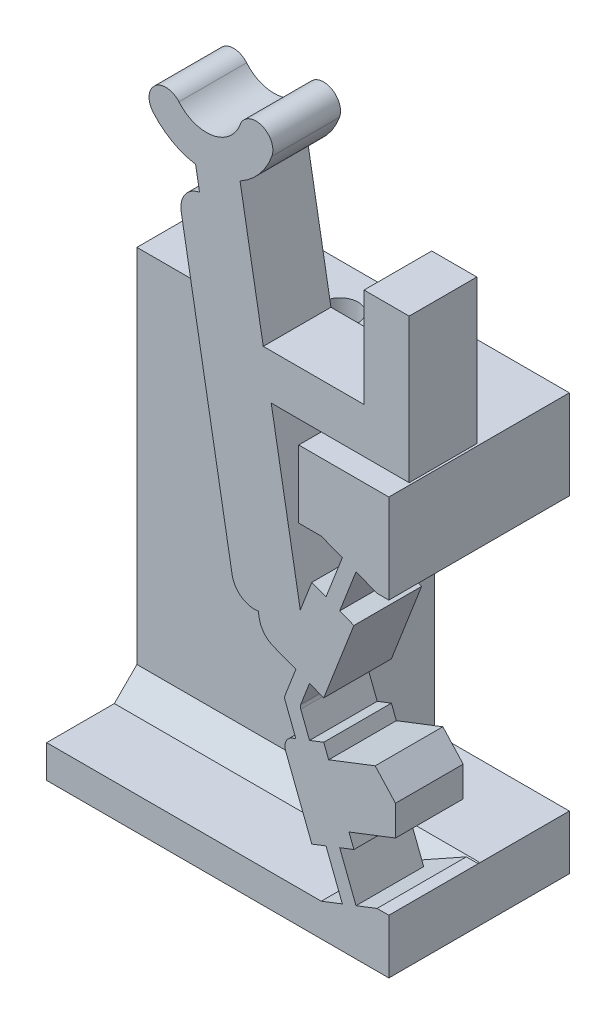
from build123d import *

# Parameters (mm, degrees)
BOSS_SWITCH_BODY_DEPTH            = 3
SKETCH1_W                         = 2.994375291
SKETCH1_H                         = 2.409101515
SKETCH1_W_2                       = 3.994375291
SKETCH1_H_2                       = 3.957767538
BOSS_FLANGE_WIDTH_DEPTH           = 5
BOSS_FLANGE_HEIGHT_REACH          = 36.354
SKETCH2_W                         = 4
SKETCH2_H                         = 3.957767538
SKETCH2_W_2                       = 8
SKETCH2_H_2                       = 1.451333978
SKETCH17_W                        = 15.1675
SKETCH17_H                        = 4
BOSS_FLANGE_SUPPORT_DEPTH         = 13.053634428
CUT_WALL_GAP_DEPTH                = 1
TAP_DRILL_FOR_M2X0_4_TAP1_D       = 1.6
M2_CLEARANCE_HOLE2_D              = 2.4
M2_CLEARANCE_HOLE2_DEPTH          = 13.462735941
CHAMFER_FLANGE_SUPPORT_3_SIZE     = 1
FILLET1_R                         = 1
FILLET2_R                         = 0.5
SKETCH28_W                        = 5.9675
SKETCH28_H                        = 12.095866891
CUT_PRINT_SUPPORT_CLEARANCE_DEPTH = 33.624103931


with BuildPart() as part:
    # Sketch-SwitchBossUp → Boss-Switch Body (new body)
    with BuildSketch(Plane.XY):
        with BuildLine():
            Line((-5.697895702, 26.949658376), (-5.524247524, 25.964850623))
            ThreePointArc((-5.524247524, 25.964850623), (-6.169751391, 25.553619307), (-6.3354071, 24.806394693))
            Line((-6.3354071, 24.806394693), (-4.07798079, 12.003893904))
            ThreePointArc((-4.07798079, 12.003893904), (-3.666749473, 11.358390037), (-2.919524859, 11.192734328))
            Line((-2.919524859, 11.192734328), (-2.775521101, 10.376048434))
            Line((-2.775521101, 10.376048434), (-1.884274871, 10.03057987))
            Line((-1.884274871, 10.03057987), (-1.254903211, 9.786620214))
            Line((-1.254903211, 9.786620214), (-1.735258621, 8.547390389))
            ThreePointArc((-1.735258621, 8.547390389), (-1.752158006, 8.457034961), (-1.735258621, 8.366679532))
            Line((-1.735258621, 8.366679532), (-1.254903211, 7.127449707))
            Line((-1.254903211, 7.127449707), (-1.884274871, 6.883490051))
            Line((-1.884274871, 6.883490051), (-0.547014535, 3.433600952))
            Line((-0.547014535, 3.433600952), (0.082357125, 3.677560608))
            Line((0.082357125, 3.677560608), (0.805200549, 1.81275569))
            Line((0.805200549, 1.81275569), (-0.12720191, 1.451333978))
            Line((-0.12720191, 1.451333978), (-0.12720191, 0))
            Line((-0.12720191, 0), (2.867173381, 0))
            Line((2.867173381, 0), (2.867173381, 2.409101515))
            Line((2.867173381, 2.409101515), (2.343664607, 2.409101515))
            Line((2.343664607, 2.409101515), (1.411262148, 2.047679803))
            Line((1.411262148, 2.047679803), (0.688418723, 3.912484721))
            Line((0.688418723, 3.912484721), (1.317790383, 4.156444377))
            Line((1.317790383, 4.156444377), (1.099194858, 4.720381179))
            Line((1.099194858, 4.720381179), (3.161331824, 5.519715271))
            Line((3.161331824, 5.519715271), (3.161331824, 6.855167315))
            Line((3.161331824, 6.855167315), (2.261147576, 7.841686204))
            Line((2.261147576, 7.841686204), (0.199125572, 7.042396674))
            Line((0.199125572, 7.042396674), (-0.019469953, 7.606333476))
            Line((-0.019469953, 7.606333476), (-0.648841612, 7.36237382))
            Line((-0.648841612, 7.36237382), (-1.038134762, 8.366679532))
            ThreePointArc((-1.038134762, 8.366679532), (-1.055034148, 8.457034961), (-1.038134762, 8.547390389))
            Line((-1.038134762, 8.547390389), (-0.648841612, 9.551696101))
            Line((-0.648841612, 9.551696101), (-0.019469953, 9.307736445))
            Line((-0.019469953, 9.307736445), (1.317790383, 12.757625544))
            Line((1.317790383, 12.757625544), (0.688418723, 13.0015852))
            Line((0.688418723, 13.0015852), (1.411262148, 14.866390118))
            Line((1.411262148, 14.866390118), (2.343664607, 14.504968406))
            Line((2.343664607, 14.504968406), (2.867173381, 14.504968406))
            Line((2.867173381, 14.504968406), (2.867173381, 18.462735944))
            Line((2.867173381, 18.462735944), (-0.111637615, 18.462735944))
            Line((-0.111637615, 18.462735944), (-1.12720191, 18.462735944))
            Line((-1.12720191, 18.462735944), (-1.12720191, 15.462735944))
            Line((-1.12720191, 15.462735944), (-0.12720191, 15.462735944))
            Line((-0.12720191, 15.462735944), (0.805200549, 15.101314231))
            Line((0.805200549, 15.101314231), (0.082357125, 13.236509313))
            Line((0.082357125, 13.236509313), (-0.547014535, 13.480468969))
            Line((-0.547014535, 13.480468969), (-1.059112089, 12.159350171))
            Line((-1.059112089, 12.159350171), (-2.346896051, 19.462735944))
            Line((-2.346896051, 19.462735944), (3.767173381, 19.462735944))
            Line((3.767173381, 19.462735944), (3.767173381, 25.857619356))
            Line((3.767173381, 25.857619356), (1.767173381, 25.857619356))
            Line((1.767173381, 25.857619356), (1.767173381, 21.462735944))
            Line((1.767173381, 21.462735944), (-2.699550012, 21.462735944))
            Line((-2.699550012, 21.462735944), (-3.728280196, 27.296954732))
            ThreePointArc((-3.728280196, 27.296954732), (-2.874356585, 27.992742953), (-2.319025652, 28.944012807))
            ThreePointArc((-2.319025652, 28.944012807), (-2.76728001, 29.905297381), (-3.728564583, 29.457043022))
            ThreePointArc((-3.728564583, 29.457043022), (-4.944660137, 28.436617692), (-6.436422172, 28.97957467))
            ThreePointArc((-6.436422172, 28.97957467), (-7.493046212, 29.072017295), (-7.585488837, 28.015393255))
            ThreePointArc((-7.585488837, 28.015393255), (-6.738295005, 27.311426358), (-5.697895702, 26.949658376))
        make_face()
    extrude(amount=BOSS_SWITCH_BODY_DEPTH)

    # Sketch1 → Boss-Flange Width (add)
    with BuildSketch(Plane(origin=(0, 0, 0), x_dir=(-1, 0, 0), z_dir=(0, 0, -1))):
        with Locations((-1.369985736, 1.204550758)):
            Rectangle(SKETCH1_W, SKETCH1_H)
        with Locations((-0.869985736, 16.483852175)):
            Rectangle(SKETCH1_W_2, SKETCH1_H_2)
    extrude(amount=BOSS_FLANGE_WIDTH_DEPTH)

    # Boss-Flange Height: up to this face of the body (flat: up to its plane)
    boss_flange_height_end = Plane(part.part.faces().sort_by_distance((-0.12720191, 1.077409098, -1.438016547))[0])
    # Sketch2 → Boss-Flange Height (add, up to the picked face)
    with BuildSketch(Plane(origin=(-12.300326619, 0, 0), x_dir=(0, 0, -1), z_dir=(1, 0, 0)), mode=Mode.PRIVATE) as boss_flange_height_sk1:
        with Locations((3, 16.483852175)):
            Rectangle(SKETCH2_W, SKETCH2_H)
    boss_flange_height_tool1 = split(extrude(boss_flange_height_sk1.sketch, amount=BOSS_FLANGE_HEIGHT_REACH, mode=Mode.PRIVATE), bisect_by=boss_flange_height_end, keep=Keep.BOTH, mode=Mode.PRIVATE)
    # Sketch2 → Boss-Flange Height (add, up to the picked face)
    with BuildSketch(Plane(origin=(-12.300326619, 0, 0), x_dir=(0, 0, -1), z_dir=(1, 0, 0)), mode=Mode.PRIVATE) as boss_flange_height_sk2:
        with Locations((1, 0.725666989)):
            Rectangle(SKETCH2_W_2, SKETCH2_H_2)
    boss_flange_height_tool2 = split(extrude(boss_flange_height_sk2.sketch, amount=BOSS_FLANGE_HEIGHT_REACH, mode=Mode.PRIVATE), bisect_by=boss_flange_height_end, keep=Keep.BOTH, mode=Mode.PRIVATE)
    add(boss_flange_height_tool1.solids().sort_by(Axis((-12.300327, 16.483852, -3), (1, 0, 0)))[0])
    add(boss_flange_height_tool2.solids().sort_by(Axis((-12.300327, 0.725667, -1), (1, 0, 0)))[0])

    # Sketch17 → Boss-Flange Support (add)
    with BuildSketch(Plane.XZ.offset(-1.451333978)):
        with Locations((-4.716576619, -3)):
            Rectangle(SKETCH17_W, SKETCH17_H)
    extrude(amount=-BOSS_FLANGE_SUPPORT_DEPTH)

    # Sketch27 → Cut-Wall Gap (cut)
    with BuildSketch(Plane.XY):
        Polygon((-0.12720191, 15.462735944), (2.343664607, 14.504968406), (-1.12720191, 14.504968406), (-1.12720191, 15.462735944), align=None)
        Polygon((2.343664607, 2.409101515), (-0.12720191, 2.409101515), (-0.12720191, 1.451333978), align=None)
    extrude(amount=-CUT_WALL_GAP_DEPTH, mode=Mode.SUBTRACT)

    # Tap Drill for M2x0.4 Tap1 (through all)
    with Locations(Plane(origin=(0, 0, 0), x_dir=(-1, 0, 0), z_dir=(0, -1, 0))):
        with Locations((9.300326619, 3), (5.300326619, 3)):
            Hole(TAP_DRILL_FOR_M2X0_4_TAP1_D / 2)

    # M2 Clearance Hole2
    with Locations(Plane.XZ):
        with Locations((-9.300326619, -3), (-5.300326619, -3)):
            Hole(M2_CLEARANCE_HOLE2_D / 2, depth=M2_CLEARANCE_HOLE2_DEPTH)

    # Chamfer-Flange Support 3
    chamfer_flange_support_3_edges = [part.edges().sort_by_distance(p)[0] for p in [
        (-6.213764264, 1.451333978, -1),
    ]]
    chamfer(chamfer_flange_support_3_edges, length=CHAMFER_FLANGE_SUPPORT_3_SIZE)

    # Fillet1
    fillet1_edges = [part.edges().sort_by_distance(p)[0] for p in [
        (-2.775521101, 10.376048434, 1.5),
    ]]
    fillet(fillet1_edges, radius=FILLET1_R)

    # Fillet2
    fillet2_edges = [part.edges().sort_by_distance(p)[0] for p in [
        (-1.884274871, 6.883490051, 1.5),
    ]]
    fillet(fillet2_edges, radius=FILLET2_R)

    # Sketch28 → Cut-Print Support Clearance (cut, through all)
    with BuildSketch(Plane.XY.offset(-1)):
        with Locations((-0.116576619, 8.457034961)):
            Rectangle(SKETCH28_W, SKETCH28_H)
    extrude(amount=-CUT_PRINT_SUPPORT_CLEARANCE_DEPTH, mode=Mode.SUBTRACT)


solid = part.part
